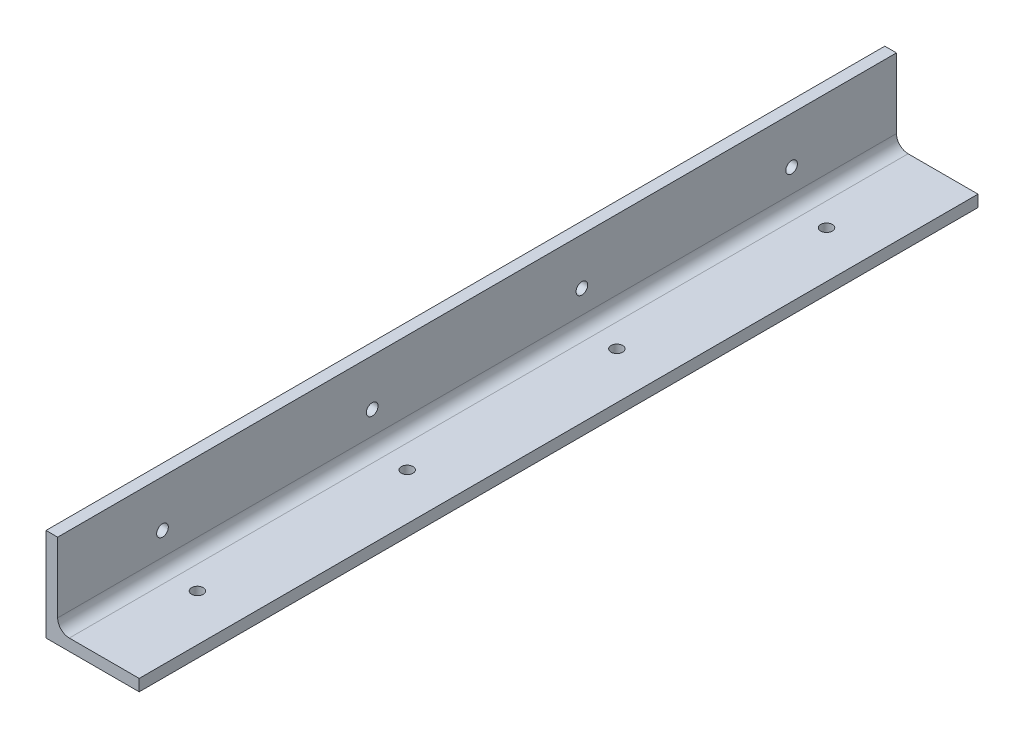
from build123d import *

# Parameters (mm, degrees)
SKETCH1_W                   = 6.35
SKETCH1_H                   = 44.45
BOSS_EXTRUDE1_DEPTH         = 457.2
FILLET1_R                   = 6.35
F_1_4_0_25_DIAMETER_HOLE1_D = 6.35
LPATTERN1_COUNT             = 4
LPATTERN1_PITCH             = 114.3
F_1_4_0_25_DIAMETER_HOLE2_D = 6.35
LPATTERN2_COUNT             = 4
LPATTERN2_PITCH             = 114.3


with BuildPart() as part:
    # Sketch1 → Boss-Extrude1 (new body)
    with BuildSketch(Plane.XY):
        with Locations((-26.434360713, 1.221912767)):
            Rectangle(SKETCH1_W, SKETCH1_H)
        Polygon((-23.259360713, -21.003087233), (-29.609360713, -21.003087233), (-29.609360713, -27.353087233), (21.190639287, -27.353087233), (21.190639287, -21.003087233), align=None)
    extrude(amount=BOSS_EXTRUDE1_DEPTH)

    # Fillet1
    fillet1_edges = [part.edges().sort_by_distance(p)[0] for p in [
        (-23.259360713, -21.003087233, 228.6),
    ]]
    fillet(fillet1_edges, radius=FILLET1_R)

    # 1/4 (0.25) Diameter Hole1 (through all)
    with Locations(Plane.XZ.offset(27.353087233)):
        with Locations((-4.209360713, 400.05)):
            f_1_4_0_25_diameter_hole1 = Hole(F_1_4_0_25_DIAMETER_HOLE1_D / 2)

    # LPattern1: 1/4 (0.25) Diameter Hole1 ×4
    with Locations(*[(0, 0, -i * LPATTERN1_PITCH) for i in range(1, LPATTERN1_COUNT)]):
        add(f_1_4_0_25_diameter_hole1, mode=Mode.SUBTRACT)

    # 1/4 (0.25) Diameter Hole2 (through all)
    with Locations(Plane.ZY.offset(29.609360713)):
        with Locations((400.05, -1.953087233)):
            f_1_4_0_25_diameter_hole2 = Hole(F_1_4_0_25_DIAMETER_HOLE2_D / 2)

    # LPattern2: 1/4 (0.25) Diameter Hole2 ×4
    with Locations(*[(0, 0, -i * LPATTERN2_PITCH) for i in range(1, LPATTERN2_COUNT)]):
        add(f_1_4_0_25_diameter_hole2, mode=Mode.SUBTRACT)


solid = part.part
